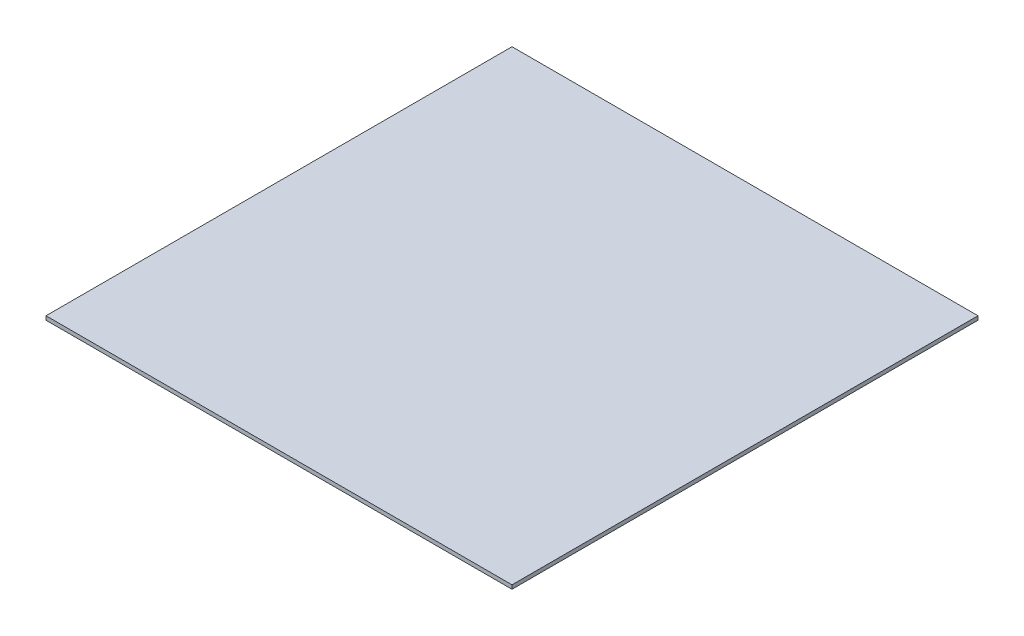
from build123d import *

# Parameters (mm, degrees)
SKETCH1_W           = 600
SKETCH1_H           = 600
BOSS_EXTRUDE1_DEPTH = 5


with BuildPart() as part:
    # Sketch1 → Boss-Extrude1 (new body)
    with BuildSketch(Plane(origin=(-19.074457196, -1092.573312588, -406.917252354), x_dir=(1, 0, 0), z_dir=(0, -1, 0))):
        Rectangle(SKETCH1_W, SKETCH1_H)
    extrude(amount=BOSS_EXTRUDE1_DEPTH)


solid = part.part
